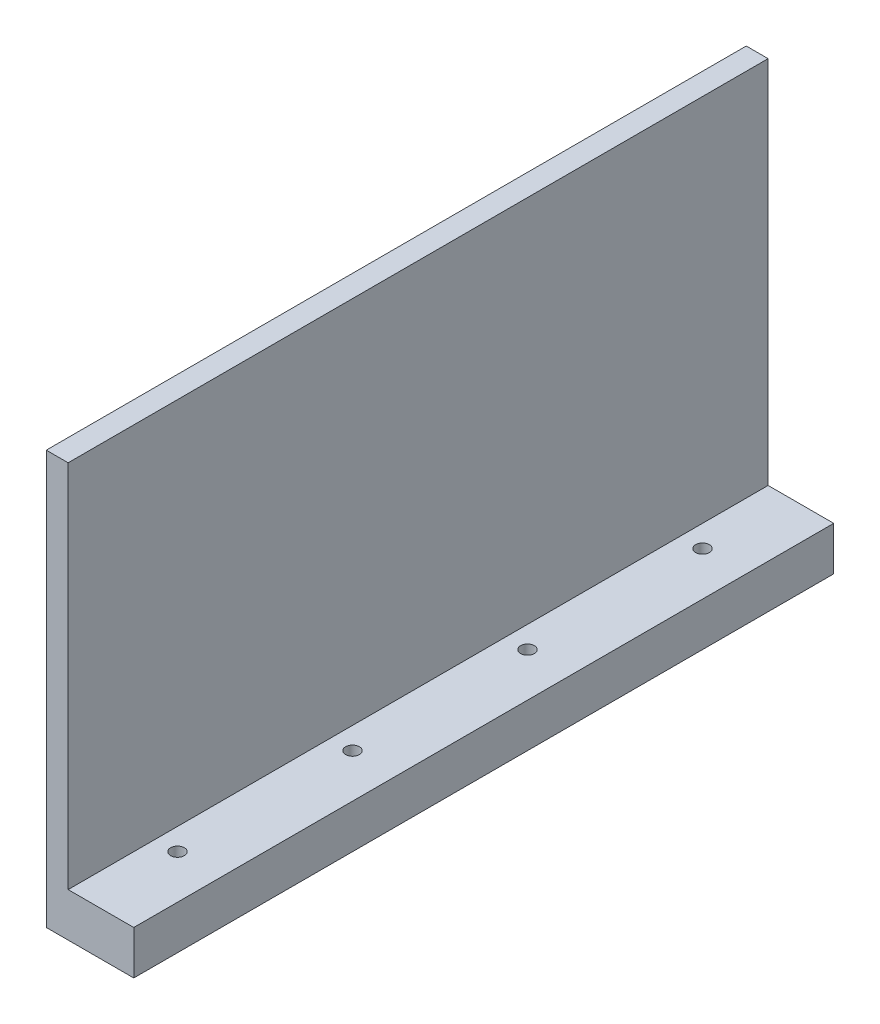
from build123d import *

# Parameters (mm, degrees)
SKETCH1_W           = 12.7
SKETCH1_H           = 101.6
BOSS_EXTRUDE1_DEPTH = 59.999999888
SKETCH2_W           = 9.525
SKETCH2_H           = 101.6
CUT_EXTRUDE1_DEPTH  = 53.65
SKETCH3_R           = 1.000000032
CUT_EXTRUDE2_DEPTH  = 7.35


with BuildPart() as part:
    # Sketch1 → Boss-Extrude1 (new body)
    with BuildSketch(Plane(origin=(0, 0, 0), x_dir=(1, 0, 0), z_dir=(0, 1, 0))):
        Rectangle(SKETCH1_W, SKETCH1_H)
    extrude(amount=BOSS_EXTRUDE1_DEPTH)

    # Sketch2 → Cut-Extrude1 (cut)
    with BuildSketch(Plane(origin=(0, 59.999999888, 0), x_dir=(1, 0, 0), z_dir=(0, 1, 0))):
        with Locations((1.5875, 0)):
            Rectangle(SKETCH2_W, SKETCH2_H)
    extrude(amount=-CUT_EXTRUDE1_DEPTH, mode=Mode.SUBTRACT)

    # Sketch3 → Cut-Extrude2 (cut, through all)
    with BuildSketch(Plane(origin=(0, 6.35, 0), x_dir=(1, 0, 0), z_dir=(0, 1, 0))):
        with Locations((0, 38.1)):
            Circle(SKETCH3_R)
        with Locations((0, 12.7)):
            Circle(SKETCH3_R)
        with Locations((0, -12.7)):
            Circle(SKETCH3_R)
        with Locations((0, -38.1)):
            Circle(SKETCH3_R)
    extrude(amount=-CUT_EXTRUDE2_DEPTH, mode=Mode.SUBTRACT)


solid = part.part
